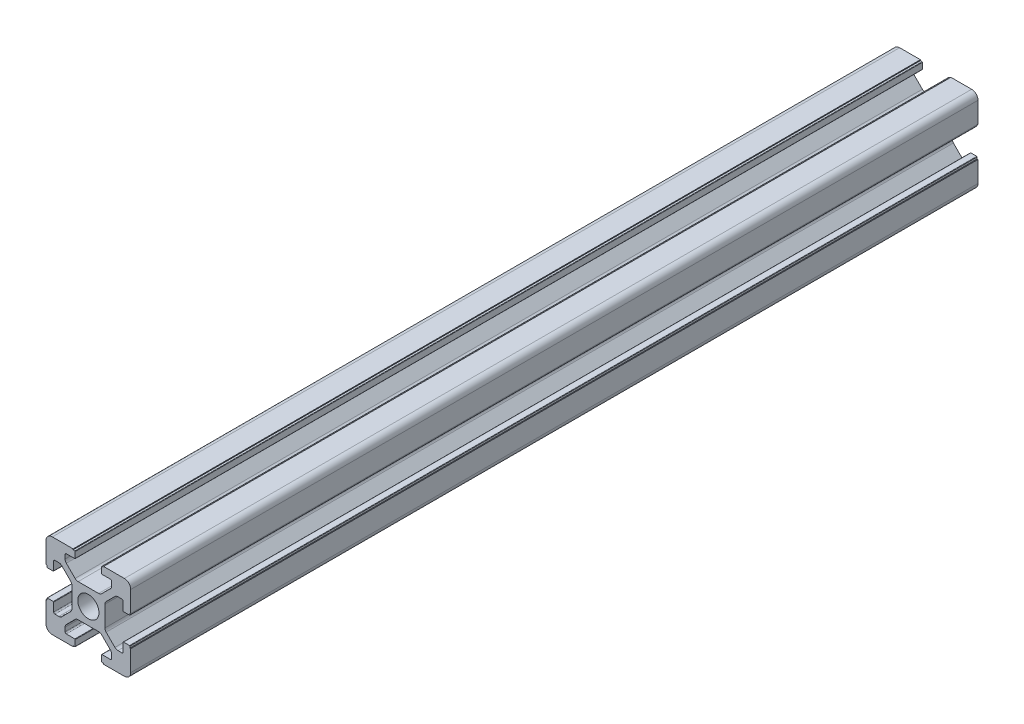
from build123d import *

# Parameters (mm, degrees)
SKETCH_1_R      = 2.5
EXTRUDE_1_DEPTH = 200
FILLET_1_R      = 1.5


with BuildPart() as part:
    # 草图1 → 凸台-拉伸1 (new body)
    with BuildSketch(Plane.XY):
        with BuildLine():
            Line((20, 13.6), (20, 20))
            Line((20, 20), (13.6, 20))
            Line((13.6, 20), (13.6, 19.8))
            Line((13.6, 19.8), (13.2, 19.8))
            ThreePointArc((13.2, 19.8), (13.129289322, 19.770710678), (13.1, 19.7))
            Line((13.1, 19.7), (13.1, 18.3))
            ThreePointArc((13.1, 18.3), (13.129289322, 18.229289322), (13.2, 18.2))
            Line((13.2, 18.2), (15.2, 18.2))
            ThreePointArc((15.2, 18.2), (15.412132034, 18.112132034), (15.5, 17.9))
            Line((15.5, 17.9), (15.5, 16.974873734))
            ThreePointArc((15.5, 16.974873734), (15.423879533, 16.592190302), (15.207106781, 16.267766953))
            Line((15.207106781, 16.267766953), (13.132233047, 14.192893219))
            ThreePointArc((13.132233047, 14.192893219), (12.807809698, 13.976120467), (12.425126266, 13.9))
            Line((12.425126266, 13.9), (7.574873734, 13.9))
            ThreePointArc((7.574873734, 13.9), (7.192190302, 13.976120467), (6.867766953, 14.192893219))
            Line((6.867766953, 14.192893219), (4.792893219, 16.267766953))
            ThreePointArc((4.792893219, 16.267766953), (4.576120467, 16.592190302), (4.5, 16.974873734))
            Line((4.5, 16.974873734), (4.5, 17.9))
            ThreePointArc((4.5, 17.9), (4.587867966, 18.112132034), (4.8, 18.2))
            Line((4.8, 18.2), (6.8, 18.2))
            ThreePointArc((6.8, 18.2), (6.870710678, 18.229289322), (6.9, 18.3))
            Line((6.9, 18.3), (6.9, 19.7))
            ThreePointArc((6.9, 19.7), (6.870710678, 19.770710678), (6.8, 19.8))
            Line((6.8, 19.8), (6.4, 19.8))
            Line((6.4, 19.8), (6.4, 20))
            Line((6.4, 20), (0, 20))
            Line((0, 20), (0, 13.6))
            Line((0, 13.6), (0.2, 13.6))
            Line((0.2, 13.6), (0.2, 13.2))
            ThreePointArc((0.2, 13.2), (0.229289322, 13.129289322), (0.3, 13.1))
            Line((0.3, 13.1), (1.7, 13.1))
            ThreePointArc((1.7, 13.1), (1.770710678, 13.129289322), (1.8, 13.2))
            Line((1.8, 13.2), (1.8, 15.2))
            ThreePointArc((1.8, 15.2), (1.887867966, 15.412132034), (2.1, 15.5))
            Line((2.1, 15.5), (3.025126266, 15.5))
            ThreePointArc((3.025126266, 15.5), (3.407809698, 15.423879533), (3.732233047, 15.207106781))
            Line((3.732233047, 15.207106781), (5.807106781, 13.132233047))
            ThreePointArc((5.807106781, 13.132233047), (6.023879533, 12.807809698), (6.1, 12.425126266))
            Line((6.1, 12.425126266), (6.1, 7.574873734))
            ThreePointArc((6.1, 7.574873734), (6.023879533, 7.192190302), (5.807106781, 6.867766953))
            Line((5.807106781, 6.867766953), (3.732233047, 4.792893219))
            ThreePointArc((3.732233047, 4.792893219), (3.407809698, 4.576120467), (3.025126266, 4.5))
            Line((3.025126266, 4.5), (2.1, 4.5))
            ThreePointArc((2.1, 4.5), (1.887867966, 4.587867966), (1.8, 4.8))
            Line((1.8, 4.8), (1.8, 6.8))
            ThreePointArc((1.8, 6.8), (1.770710678, 6.870710678), (1.7, 6.9))
            Line((1.7, 6.9), (0.3, 6.9))
            ThreePointArc((0.3, 6.9), (0.229289322, 6.870710678), (0.2, 6.8))
            Line((0.2, 6.8), (0.2, 6.4))
            Line((0.2, 6.4), (0, 6.4))
            Line((0, 6.4), (0, 0))
            Line((0, 0), (6.4, 0))
            Line((6.4, 0), (6.4, 0.2))
            Line((6.4, 0.2), (6.8, 0.2))
            ThreePointArc((6.8, 0.2), (6.870710678, 0.229289322), (6.9, 0.3))
            Line((6.9, 0.3), (6.9, 1.7))
            ThreePointArc((6.9, 1.7), (6.870710678, 1.770710678), (6.8, 1.8))
            Line((6.8, 1.8), (4.8, 1.8))
            ThreePointArc((4.8, 1.8), (4.587867966, 1.887867966), (4.5, 2.1))
            Line((4.5, 2.1), (4.5, 3.025126266))
            ThreePointArc((4.5, 3.025126266), (4.576120467, 3.407809698), (4.792893219, 3.732233047))
            Line((4.792893219, 3.732233047), (6.867766953, 5.807106781))
            ThreePointArc((6.867766953, 5.807106781), (7.192190302, 6.023879533), (7.574873734, 6.1))
            Line((7.574873734, 6.1), (12.425126266, 6.1))
            ThreePointArc((12.425126266, 6.1), (12.807809698, 6.023879533), (13.132233047, 5.807106781))
            Line((13.132233047, 5.807106781), (15.207106781, 3.732233047))
            ThreePointArc((15.207106781, 3.732233047), (15.423879533, 3.407809698), (15.5, 3.025126266))
            Line((15.5, 3.025126266), (15.5, 2.1))
            ThreePointArc((15.5, 2.1), (15.412132034, 1.887867966), (15.2, 1.8))
            Line((15.2, 1.8), (13.2, 1.8))
            ThreePointArc((13.2, 1.8), (13.129289322, 1.770710678), (13.1, 1.7))
            Line((13.1, 1.7), (13.1, 0.3))
            ThreePointArc((13.1, 0.3), (13.129289322, 0.229289322), (13.2, 0.2))
            Line((13.2, 0.2), (13.6, 0.2))
            Line((13.6, 0.2), (13.6, 0))
            Line((13.6, 0), (20, 0))
            Line((20, 0), (20, 6.4))
            Line((20, 6.4), (19.8, 6.4))
            Line((19.8, 6.4), (19.8, 6.8))
            ThreePointArc((19.8, 6.8), (19.770710678, 6.870710678), (19.7, 6.9))
            Line((19.7, 6.9), (18.3, 6.9))
            ThreePointArc((18.3, 6.9), (18.229289322, 6.870710678), (18.2, 6.8))
            Line((18.2, 6.8), (18.2, 4.8))
            ThreePointArc((18.2, 4.8), (18.112132034, 4.587867966), (17.9, 4.5))
            Line((17.9, 4.5), (16.974873734, 4.5))
            ThreePointArc((16.974873734, 4.5), (16.592190302, 4.576120467), (16.267766953, 4.792893219))
            Line((16.267766953, 4.792893219), (14.192893219, 6.867766953))
            ThreePointArc((14.192893219, 6.867766953), (13.976120467, 7.192190302), (13.9, 7.574873734))
            Line((13.9, 7.574873734), (13.9, 12.425126266))
            ThreePointArc((13.9, 12.425126266), (13.976120467, 12.807809698), (14.192893219, 13.132233047))
            Line((14.192893219, 13.132233047), (16.267766953, 15.207106781))
            ThreePointArc((16.267766953, 15.207106781), (16.592190302, 15.423879533), (16.974873734, 15.5))
            Line((16.974873734, 15.5), (17.9, 15.5))
            ThreePointArc((17.9, 15.5), (18.112132034, 15.412132034), (18.2, 15.2))
            Line((18.2, 15.2), (18.2, 13.2))
            ThreePointArc((18.2, 13.2), (18.229289322, 13.129289322), (18.3, 13.1))
            Line((18.3, 13.1), (19.7, 13.1))
            ThreePointArc((19.7, 13.1), (19.770710678, 13.129289322), (19.8, 13.2))
            Line((19.8, 13.2), (19.8, 13.6))
            Line((19.8, 13.6), (20, 13.6))
        make_face()
        with Locations((10, 10)):
            Circle(SKETCH_1_R, mode=Mode.SUBTRACT)
    extrude(amount=EXTRUDE_1_DEPTH)

    # 圆角1
    fillet_1_edges = [part.edges().sort_by_distance(p)[0] for p in [
        (0, 0, 100),
        (0, 20, 100),
        (20, 20, 100),
        (20, 0, 100),
    ]]
    fillet(fillet_1_edges, radius=FILLET_1_R)


solid = part.part
